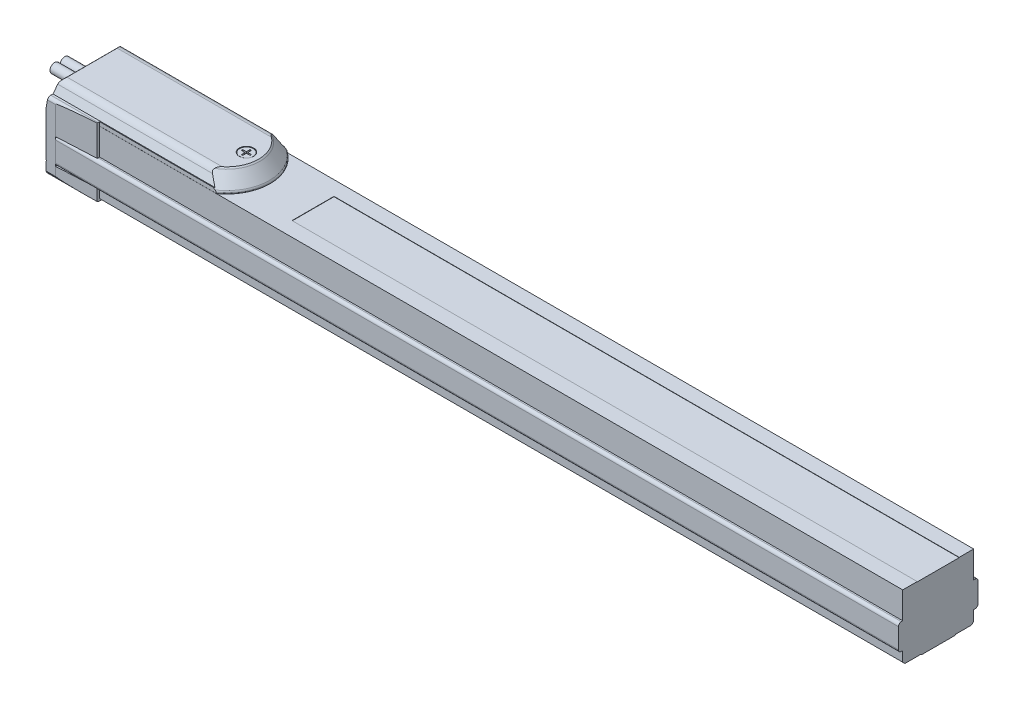
from build123d import *

# Parameters (mm, degrees)
BOSS_EXTRUDE1_DEPTH          = 930
SKETCH2_W                    = 204.786284779
SKETCH2_H                    = 168.647528641
CUT_EXTRUDE1_DEPTH           = 909.5
SKETCH3_W                    = 400
SKETCH3_H                    = 200
CUT_EXTRUDE2_DEPTH           = 930
BOSS_EXTRUDE2_DEPTH          = 127.35
CUT_REVOLVE1_ANGLE           = 75
CUT_REVOLVE1_OTHER_WAY_ANGLE = 75
CUT_EXTRUDE4_DEPTH           = 20
CUT_EXTRUDE5_DEPTH           = 1
CUT_EXTRUDE6_DEPTH           = 20
CUT_EXTRUDE6_DEPTH_BACK      = 20
CUT_EXTRUDE7_DEPTH           = 6
BOSS_EXTRUDE8_DEPTH          = 21.2
CUT_EXTRUDE9_DEPTH           = 30
CUT_EXTRUDE9_DEPTH_BACK      = 30
CUT_EXTRUDE10_DEPTH          = 2
CUT_EXTRUDE10_DEPTH_BACK     = 2
SKETCH14_R                   = 3.25
BOSS_EXTRUDE3_DEPTH          = 20
SKETCH15_R                   = 3.25
BOSS_EXTRUDE4_DEPTH          = 20
BOSS_EXTRUDE5_DEPTH          = 8.56
SKETCH17_W                   = 235.37802201
SKETCH17_H                   = 195.027503951
CUT_EXTRUDE14_DEPTH          = 40
BOSS_EXTRUDE6_DEPTH          = 18.5
BOSS_EXTRUDE7_DEPTH          = 8.56
SKETCH20_W                   = 235.37802201
SKETCH20_H                   = 195.027503951
CUT_EXTRUDE17_DEPTH          = 50
CUT_EXTRUDE18_DEPTH          = 3
SKETCH23_W                   = 742
SKETCH23_H                   = 29
CUT_EXTRUDE19_DEPTH          = 0.2
CUT_EXTRUDE20_DEPTH          = 25
CUT_EXTRUDE20_DEPTH_BACK     = 25
CUT_EXTRUDE21_DEPTH          = 16
CUT_EXTRUDE22_DEPTH          = 16
CUT_EXTRUDE23_DEPTH          = 34
CUT_EXTRUDE24_DEPTH          = 34
CUT_EXTRUDE25_DEPTH          = 16
CUT_EXTRUDE26_DEPTH          = 16
CUT_EXTRUDE27_DEPTH          = 12.5
CUT_EXTRUDE28_DEPTH          = 12.5
SKETCH_1_W                   = 185.367516804
SKETCH_1_H                   = 126.71742042
CUT_EXTRUDE_1_DEPTH          = 341


with BuildPart() as part:
    # Sketch1 → Boss-Extrude1 (new body)
    with BuildSketch(Plane(origin=(0, 0, 0), x_dir=(0, 0, -1), z_dir=(1, 0, 0))):
        with BuildLine():
            Line((-28.5, 46), (-28.5, 2.971392601))
            Line((-28.5, 2.971392601), (-27.5, 2.971392601))
            Line((-27.5, 2.971392601), (-27.328427125, 2.5))
            ThreePointArc((-27.328427125, 2.5), (-26.232050808, 1.050510257), (-24.5, 0.5))
            Line((-24.5, 0.5), (-12, 0.5))
            Line((-12, 0.5), (-11.5, 0))
            Line((-11.5, 0), (11.5, 0))
            Line((11.5, 0), (12, 0.5))
            Line((12, 0.5), (24.5, 0.5))
            ThreePointArc((24.5, 0.5), (26.232050808, 1.050510257), (27.328427125, 2.5))
            Line((27.328427125, 2.5), (27.5, 2.971392601))
            Line((27.5, 2.971392601), (28.5, 2.971392601))
            Line((28.5, 2.971392601), (28.5, 46))
            Line((28.5, 46), (27.5, 46))
            ThreePointArc((27.5, 46), (26.914213562, 47.414213562), (25.5, 48))
            Line((25.5, 48), (21.524012172, 48))
            ThreePointArc((21.524012172, 48), (17.477101448, 49.71603425), (13.295111884, 51.07))
            Line((13.295111884, 51.07), (-13.295111884, 51.07))
            ThreePointArc((-13.295111884, 51.07), (-17.477101448, 49.71603425), (-21.524012172, 48))
            Line((-21.524012172, 48), (-25.5, 48))
            ThreePointArc((-25.5, 48), (-26.914213562, 47.414213562), (-27.5, 46))
            Line((-27.5, 46), (-28.5, 46))
        make_face()
    extrude(amount=BOSS_EXTRUDE1_DEPTH)

    # Sketch2 → Cut-Extrude1 (cut)
    with BuildSketch(Plane(origin=(916, 0, 0), x_dir=(0, 0, -1), z_dir=(1, 0, 0))):
        with Locations((9.532349098, 15.424002622)):
            Rectangle(SKETCH2_W, SKETCH2_H)
        with BuildLine():
            Line((-27.5, 24.8), (-27.5, 11))
            ThreePointArc((-27.5, 11), (-26.914213562, 9.585786438), (-25.5, 9))
            Line((-25.5, 9), (-24.5, 9))
            Line((-24.5, 9), (-24.5, 2))
            Line((-24.5, 2), (-22.5, 0))
            Line((-22.5, 0), (22.5, 0))
            Line((22.5, 0), (24.5, 2))
            Line((24.5, 2), (24.5, 9))
            Line((24.5, 9), (25.5, 9))
            ThreePointArc((25.5, 9), (26.914213562, 9.585786438), (27.5, 11))
            Line((27.5, 11), (27.5, 24.8))
            ThreePointArc((27.5, 24.8), (26.914213562, 26.214213562), (25.5, 26.8))
            Line((25.5, 26.8), (24.5, 26.8))
            Line((24.5, 26.8), (24.5, 45.3))
            Line((24.5, 45.3), (-24.5, 45.3))
            Line((-24.5, 45.3), (-24.5, 26.8))
            Line((-24.5, 26.8), (-25.5, 26.8))
            ThreePointArc((-25.5, 26.8), (-26.914213562, 26.214213562), (-27.5, 24.8))
        make_face(mode=Mode.SUBTRACT)
    extrude(amount=-CUT_EXTRUDE1_DEPTH, mode=Mode.SUBTRACT)

    # Sketch3 → Cut-Extrude2 (cut)
    with BuildSketch(Plane(origin=(0, 0, 0), x_dir=(0, 0, -1), z_dir=(1, 0, 0))):
        Rectangle(SKETCH3_W, SKETCH3_H)
        with BuildLine():
            Line((-27.5, 46), (-27.5, 2.971392601))
            Line((-27.5, 2.971392601), (-27.328427125, 2.5))
            ThreePointArc((-27.328427125, 2.5), (-26.232050808, 1.050510257), (-24.5, 0.5))
            Line((-24.5, 0.5), (-12, 0.5))
            Line((-12, 0.5), (-11.5, 0))
            Line((-11.5, 0), (11.5, 0))
            Line((11.5, 0), (12, 0.5))
            Line((12, 0.5), (24.5, 0.5))
            ThreePointArc((24.5, 0.5), (26.232050808, 1.050510257), (27.328427125, 2.5))
            Line((27.328427125, 2.5), (27.5, 2.971392601))
            Line((27.5, 2.971392601), (27.5, 46))
            ThreePointArc((27.5, 46), (26.914213562, 47.414213562), (25.5, 48))
            Line((25.5, 48), (21.524012172, 48))
            ThreePointArc((21.524012172, 48), (17.477101448, 49.71603425), (13.295111884, 51.07))
            Line((13.295111884, 51.07), (-13.295111884, 51.07))
            ThreePointArc((-13.295111884, 51.07), (-17.477101448, 49.71603425), (-21.524012172, 48))
            Line((-21.524012172, 48), (-25.5, 48))
            ThreePointArc((-25.5, 48), (-26.914213562, 47.414213562), (-27.5, 46))
        make_face(mode=Mode.SUBTRACT)
    extrude(amount=CUT_EXTRUDE2_DEPTH, mode=Mode.SUBTRACT)

    # Sketch4 → Boss-Extrude2 (add)
    with BuildSketch(Plane(origin=(0, 0, 0), x_dir=(0, 0, -1), z_dir=(1, 0, 0))):
        with BuildLine():
            Line((-24.5, 30), (24.5, 30))
            Line((24.5, 30), (24.5, 45.3))
            Line((24.5, 45.3), (24.45, 45.3))
            Line((24.45, 45.3), (24.5, 45.35))
            Line((24.5, 45.35), (24.5, 48))
            Line((24.5, 48), (24, 48))
            Line((24, 48), (22.285663539, 52.710100717))
            ThreePointArc((22.285663539, 52.710100717), (20.455082617, 55.095760221), (17.587200435, 56))
            Line((17.587200435, 56), (-17.084187431, 56))
            ThreePointArc((-17.084187431, 56), (-19.770685472, 55.216957229), (-21.615726366, 53.113091309))
            Line((-21.615726366, 53.113091309), (-24, 48))
            Line((-24, 48), (-24.5, 48))
            Line((-24.5, 48), (-24.5, 45.35))
            Line((-24.5, 45.35), (-24.45, 45.3))
            Line((-24.45, 45.3), (-24.5, 45.3))
            Line((-24.5, 45.3), (-24.5, 30))
        make_face()
    extrude(amount=BOSS_EXTRUDE2_DEPTH)

    # Sketch5 → Cut-Revolve1 (revolve, cut)
    with BuildSketch(Plane.XY):
        with BuildLine():
            Line((97.35, 71.971261171), (150, 71.971261171))
            Line((150, 71.971261171), (150, 45.3))
            Line((150, 45.3), (127.35, 45.3))
            Line((127.35, 45.3), (127.35, 45.79))
            ThreePointArc((127.35, 45.79), (127.234272347, 46.460460828), (126.900482278, 47.053330799))
            Line((126.900482278, 47.053330799), (120.296542673, 55.158326997))
            ThreePointArc((120.296542673, 55.158326997), (118.566072869, 56.516172881), (116.420336979, 57))
            Line((116.420336979, 57), (97.35, 57))
            Line((97.35, 57), (97.35, 71.971261171))
        make_face()
    revolve(axis=Axis((97.35, 57, 0), (0, 1, 0)), revolution_arc=CUT_REVOLVE1_ANGLE, mode=Mode.SUBTRACT)

    # Sketch5 → Cut-Revolve1 other way (revolve, cut)
    with BuildSketch(Plane.XY):
        with BuildLine():
            Line((97.35, 71.971261171), (150, 71.971261171))
            Line((150, 71.971261171), (150, 45.3))
            Line((150, 45.3), (127.35, 45.3))
            Line((127.35, 45.3), (127.35, 45.79))
            ThreePointArc((127.35, 45.79), (127.234272347, 46.460460828), (126.900482278, 47.053330799))
            Line((126.900482278, 47.053330799), (120.296542673, 55.158326997))
            ThreePointArc((120.296542673, 55.158326997), (118.566072869, 56.516172881), (116.420336979, 57))
            Line((116.420336979, 57), (97.35, 57))
            Line((97.35, 57), (97.35, 71.971261171))
        make_face()
    revolve(axis=Axis((97.35, 57, 0), (0, -1, 0)), revolution_arc=CUT_REVOLVE1_OTHER_WAY_ANGLE, mode=Mode.SUBTRACT)

    # Sketch6 → Cut-Extrude4 (cut)
    with BuildSketch(Plane(origin=(0, 48, 0), x_dir=(-1, 0, 0), z_dir=(0, 1, 0))):
        Polygon((-916, 8.7), (-916.72022238, 8.7), (-926.5, 3.5), (-926.5, -3.5), (-916.72022238, -8.7), (-916, -8.7), align=None)
    extrude(amount=CUT_EXTRUDE4_DEPTH, mode=Mode.SUBTRACT)

    # Sketch7 → Revolve1 (revolve)
    with BuildSketch(Plane.XY):
        Polygon((921.5, 48), (918.5, 48), (918.5, 50.292893219), (919.207106781, 51), (921.5, 51), align=None)
    revolve(axis=Axis((921.5, 51, 0), (0, -1, 0)))

    # Sketch8 → Cut-Extrude5 (cut)
    with BuildSketch(Plane(origin=(0, 51, 0), x_dir=(-1, 0, 0), z_dir=(0, 1, 0))):
        with BuildLine():
            Line((-923.071623365, -0.3), (-921.8, -0.3))
            Line((-921.8, -0.3), (-921.8, -1.571623365))
            ThreePointArc((-921.8, -1.571623365), (-921.5, -1.6), (-921.2, -1.571623365))
            Line((-921.2, -1.571623365), (-921.2, -0.3))
            Line((-921.2, -0.3), (-919.928376635, -0.3))
            ThreePointArc((-919.928376635, -0.3), (-919.9, 0), (-919.928376635, 0.3))
            Line((-919.928376635, 0.3), (-921.2, 0.3))
            Line((-921.2, 0.3), (-921.2, 1.571623365))
            ThreePointArc((-921.2, 1.571623365), (-921.5, 1.6), (-921.8, 1.571623365))
            Line((-921.8, 1.571623365), (-921.8, 0.3))
            Line((-921.8, 0.3), (-923.071623365, 0.3))
            ThreePointArc((-923.071623365, 0.3), (-923.1, 0), (-923.071623365, -0.3))
        make_face()
    extrude(amount=-CUT_EXTRUDE5_DEPTH, mode=Mode.SUBTRACT)

    # Sketch9 → Cut-Extrude6 (cut, two sides)
    with BuildSketch(Plane.XY) as cut_extrude6_sk:
        Polygon((-50, 0.5), (-50, 0), (79, 0), (78.5, 0.5), align=None)
    extrude(amount=CUT_EXTRUDE6_DEPTH, mode=Mode.SUBTRACT)
    extrude(cut_extrude6_sk.sketch, amount=-CUT_EXTRUDE6_DEPTH_BACK, mode=Mode.SUBTRACT)

    # Sketch10 → Cut-Extrude7 (cut)
    with BuildSketch(Plane(origin=(0, 0, 0), x_dir=(-1, 0, 0), z_dir=(0, 1, 0))):
        with BuildLine():
            Line((-625.5, 2), (-627.5, 2))
            ThreePointArc((-627.5, 2), (-629.5, 0), (-627.5, -2))
            Line((-627.5, -2), (-625.5, -2))
            ThreePointArc((-625.5, -2), (-623.5, 0), (-625.5, 2))
        make_face()
    extrude(amount=CUT_EXTRUDE7_DEPTH, mode=Mode.SUBTRACT)

    # Sketch11 → Boss-Extrude8 (add)
    with BuildSketch(Plane(origin=(0, 26.8, 0), x_dir=(-1, 0, 0), z_dir=(0, 1, 0))):
        Polygon((0, 27.5), (-6, 27.5), (-34, 26.1), (-34, -26.1), (-6, -27.5), (0, -27.5), align=None)
    extrude(amount=BOSS_EXTRUDE8_DEPTH)

    # Sketch12 → Cut-Extrude9 (cut, two sides)
    with BuildSketch(Plane.XY) as cut_extrude9_sk:
        with BuildLine():
            Line((-20, -15), (15, -15))
            Line((15, -15), (15, 0))
            Line((15, 0), (5.587775501, 0))
            ThreePointArc((5.587775501, 0), (2.209824463, 1.313613316), (0.60680201, 4.564221286))
            Line((0.60680201, 4.564221286), (0, 11.5))
            Line((0, 11.5), (0, 40.45))
            Line((0, 40.45), (2.189670922, 52.868240888))
            ThreePointArc((2.189670922, 52.868240888), (3.899771638, 55.830222216), (7.113709687, 57))
            Line((7.113709687, 57), (15, 57))
            Line((15, 57), (15, 60))
            Line((15, 60), (-20, 60))
            Line((-20, 60), (-20, -15))
        make_face()
    extrude(amount=CUT_EXTRUDE9_DEPTH, mode=Mode.SUBTRACT)
    extrude(cut_extrude9_sk.sketch, amount=-CUT_EXTRUDE9_DEPTH_BACK, mode=Mode.SUBTRACT)

    # Sketch13 → Cut-Extrude10 (cut, two sides)
    with BuildSketch(Plane(origin=(0, 0, 0), x_dir=(0, 0, -1), z_dir=(1, 0, 0))) as cut_extrude10_sk:
        with BuildLine():
            Line((-10, 46.95), (-10, 42.95))
            ThreePointArc((-10, 42.95), (-8.535533906, 39.414466094), (-5, 37.95))
            Line((-5, 37.95), (5, 37.95))
            ThreePointArc((5, 37.95), (8.535533906, 39.414466094), (10, 42.95))
            Line((10, 42.95), (10, 46.95))
            ThreePointArc((10, 46.95), (9.707106781, 47.657106781), (9, 47.95))
            Line((9, 47.95), (-9, 47.95))
            ThreePointArc((-9, 47.95), (-9.707106781, 47.657106781), (-10, 46.95))
        make_face()
    extrude(amount=CUT_EXTRUDE10_DEPTH, mode=Mode.SUBTRACT)
    extrude(cut_extrude10_sk.sketch, amount=-CUT_EXTRUDE10_DEPTH_BACK, mode=Mode.SUBTRACT)

    # Sketch14 → Boss-Extrude3 (add)
    with BuildSketch(Plane(origin=(2, 0, 0), x_dir=(0, 0, -1), z_dir=(1, 0, 0))):
        with Locations((-3.5, 43.7)):
            Circle(SKETCH14_R)
    extrude(amount=-BOSS_EXTRUDE3_DEPTH)

    # Sketch15 → Boss-Extrude4 (add)
    with BuildSketch(Plane(origin=(2, 0, 0), x_dir=(0, 0, -1), z_dir=(1, 0, 0))):
        with Locations((3.5, 43.7)):
            Circle(SKETCH15_R)
    extrude(amount=-BOSS_EXTRUDE4_DEPTH)

    # Sketch16 → Boss-Extrude5 (add)
    with BuildSketch(Plane(origin=(0, 9, 0), x_dir=(-1, 0, 0), z_dir=(0, 1, 0))):
        Polygon((0, 27.5), (-6, 27.5), (-34, 26.1), (-34, -26.1), (-6, -27.5), (0, -27.5), align=None)
    extrude(amount=-BOSS_EXTRUDE5_DEPTH)

    # Sketch17 → Cut-Extrude14 (cut)
    with BuildSketch(Plane(origin=(0, 0, 0), x_dir=(0, 0, -1), z_dir=(1, 0, 0))):
        with Locations((8.296344577, 18.152881027)):
            Rectangle(SKETCH17_W, SKETCH17_H)
        with BuildLine():
            Line((-27.5, 46), (-27.5, 2.971392601))
            Line((-27.5, 2.971392601), (-27.328427125, 2.5))
            ThreePointArc((-27.328427125, 2.5), (-26.232050808, 1.050510257), (-24.5, 0.5))
            Line((-24.5, 0.5), (24.5, 0.5))
            ThreePointArc((24.5, 0.5), (26.232050808, 1.050510257), (27.328427125, 2.5))
            Line((27.328427125, 2.5), (27.5, 2.971392601))
            Line((27.5, 2.971392601), (27.5, 46))
            ThreePointArc((27.5, 46), (26.914213562, 47.414213562), (25.5, 48))
            Line((25.5, 48), (24, 48))
            Line((24, 48), (24, 65))
            Line((24, 65), (-24, 65))
            Line((-24, 65), (-24, 48))
            Line((-24, 48), (-25.5, 48))
            ThreePointArc((-25.5, 48), (-26.914213562, 47.414213562), (-27.5, 46))
        make_face(mode=Mode.SUBTRACT)
    extrude(amount=CUT_EXTRUDE14_DEPTH, mode=Mode.SUBTRACT)

    # Sketch18 → Boss-Extrude6 (add)
    with BuildSketch(Plane(origin=(0, 26.8, 0), x_dir=(-1, 0, 0), z_dir=(0, 1, 0))):
        Polygon((-889, 26.1), (-917, 27.5), (-923, 27.5), (-923, -27.5), (-917, -27.5), (-889, -26.1), align=None)
    extrude(amount=BOSS_EXTRUDE6_DEPTH)

    # Sketch19 → Boss-Extrude7 (add)
    with BuildSketch(Plane(origin=(0, 9, 0), x_dir=(-1, 0, 0), z_dir=(0, 1, 0))):
        Polygon((-889, 26.1), (-917, 27.5), (-930, 27.5), (-930, -27.5), (-917, -27.5), (-889, -26.1), align=None)
    extrude(amount=-BOSS_EXTRUDE7_DEPTH)

    # Sketch20 → Cut-Extrude17 (cut)
    with BuildSketch(Plane(origin=(930, 0, 0), x_dir=(0, 0, -1), z_dir=(1, 0, 0))):
        with Locations((8.296344577, 18.152881027)):
            Rectangle(SKETCH20_W, SKETCH20_H)
        with BuildLine():
            Line((-27.5, 46), (-27.5, 2.971392601))
            Line((-27.5, 2.971392601), (-27.328427125, 2.5))
            ThreePointArc((-27.328427125, 2.5), (-26.232050808, 1.050510257), (-24.5, 0.5))
            Line((-24.5, 0.5), (-12, 0.5))
            Line((-12, 0.5), (-11.5, 0))
            Line((-11.5, 0), (11.5, 0))
            Line((11.5, 0), (12, 0.5))
            Line((12, 0.5), (24.5, 0.5))
            ThreePointArc((24.5, 0.5), (26.232050808, 1.050510257), (27.328427125, 2.5))
            Line((27.328427125, 2.5), (27.5, 2.971392601))
            Line((27.5, 2.971392601), (27.5, 46))
            ThreePointArc((27.5, 46), (26.914213562, 47.414213562), (25.5, 48))
            Line((25.5, 48), (24, 48))
            Line((24, 48), (24, 65))
            Line((24, 65), (-24, 65))
            Line((-24, 65), (-24, 48))
            Line((-24, 48), (-25.5, 48))
            ThreePointArc((-25.5, 48), (-26.914213562, 47.414213562), (-27.5, 46))
        make_face(mode=Mode.SUBTRACT)
    extrude(amount=-CUT_EXTRUDE17_DEPTH, mode=Mode.SUBTRACT)

    # Sketch21 → Cut-Revolve2 (revolve, cut)
    with BuildSketch(Plane.XY):
        Polygon((111, 60.83306822), (116, 60.83306822), (116, 55.5), (115.7, 55.8), (111, 55.8), align=None)
    revolve(axis=Axis((111, 55.8, 0), (0, 1, 0)), mode=Mode.SUBTRACT)

    # Sketch22 → Cut-Extrude18 (cut)
    with BuildSketch(Plane(origin=(0, 55.8, 0), x_dir=(-1, 0, 0), z_dir=(0, 1, 0))):
        with BuildLine():
            Line((-108.041960108, 0.5), (-110.5, 0.5))
            Line((-110.5, 0.5), (-110.5, 2.958039892))
            ThreePointArc((-110.5, 2.958039892), (-111, 3), (-111.5, 2.958039892))
            Line((-111.5, 2.958039892), (-111.5, 0.5))
            Line((-111.5, 0.5), (-113.958039892, 0.5))
            ThreePointArc((-113.958039892, 0.5), (-114, 0), (-113.958039892, -0.5))
            Line((-113.958039892, -0.5), (-111.5, -0.5))
            Line((-111.5, -0.5), (-111.5, -2.958039892))
            ThreePointArc((-111.5, -2.958039892), (-111, -3), (-110.5, -2.958039892))
            Line((-110.5, -2.958039892), (-110.5, -0.5))
            Line((-110.5, -0.5), (-108.041960108, -0.5))
            ThreePointArc((-108.041960108, -0.5), (-108, 0), (-108.041960108, 0.5))
        make_face()
    extrude(amount=-CUT_EXTRUDE18_DEPTH, mode=Mode.SUBTRACT)

    # Sketch23 → Cut-Extrude19 (cut)
    with BuildSketch(Plane(origin=(0, 45.3, 0), x_dir=(-1, 0, 0), z_dir=(0, 1, 0))):
        with Locations((-528, 0)):
            Rectangle(SKETCH23_W, SKETCH23_H)
    extrude(amount=-CUT_EXTRUDE19_DEPTH, mode=Mode.SUBTRACT)

    # Sketch24 → Cut-Revolve3 (revolve, cut)
    with BuildSketch(Plane.XY):
        Polygon((126.5, 0), (124.5, 0), (124.5, 6), (126.5, 7.154700538), align=None)
    revolve(axis=Axis((126.5, 7.154700538, 0), (0, -1, 0)), mode=Mode.SUBTRACT)

    # Sketch25 → Cut-Revolve4 (revolve, cut)
    with BuildSketch(Plane(origin=(101.5, 0, 0), x_dir=(0, 0, -1), z_dir=(1, 0, 0))):
        Polygon((0, 11.019415637), (2.4585, 9.6), (2.4585, 0.5415), (3, 0), (0, 0), align=None)
    revolve(axis=Axis((101.5, 0, 0), (0, 1, 0)), mode=Mode.SUBTRACT)

    # Sketch26 → Cut-Revolve5 (revolve, cut)
    with BuildSketch(Plane(origin=(901.5, 0, 0), x_dir=(0, 0, -1), z_dir=(1, 0, 0))):
        Polygon((0, 11.019415637), (2.4585, 9.6), (2.4585, 0.5415), (3, 0), (0, 0), align=None)
    revolve(axis=Axis((901.5, 0, 0), (0, 1, 0)), mode=Mode.SUBTRACT)

    # Sketch27 → Cut-Revolve6 (revolve, cut)
    with BuildSketch(Plane(origin=(851.5, 0, 0), x_dir=(0, 0, -1), z_dir=(1, 0, 0))):
        Polygon((0, 11.019415637), (2.4585, 9.6), (2.4585, 0.5415), (3, 0), (0, 0), align=None)
    revolve(axis=Axis((851.5, 0, 0), (0, 1, 0)), mode=Mode.SUBTRACT)

    # Sketch28 → Cut-Revolve7 (revolve, cut)
    with BuildSketch(Plane(origin=(801.5, 0, 0), x_dir=(0, 0, -1), z_dir=(1, 0, 0))):
        Polygon((0, 11.019415637), (2.4585, 9.6), (2.4585, 0.5415), (3, 0), (0, 0), align=None)
    revolve(axis=Axis((801.5, 0, 0), (0, 1, 0)), mode=Mode.SUBTRACT)

    # Sketch29 → Cut-Revolve8 (revolve, cut)
    with BuildSketch(Plane(origin=(751.5, 0, 0), x_dir=(0, 0, -1), z_dir=(1, 0, 0))):
        Polygon((0, 11.019415637), (2.4585, 9.6), (2.4585, 0.5415), (3, 0), (0, 0), align=None)
    revolve(axis=Axis((751.5, 0, 0), (0, 1, 0)), mode=Mode.SUBTRACT)

    # Sketch30 → Cut-Revolve9 (revolve, cut)
    with BuildSketch(Plane(origin=(701.5, 0, 0), x_dir=(0, 0, -1), z_dir=(1, 0, 0))):
        Polygon((0, 11.019415637), (2.4585, 9.6), (2.4585, 0.5415), (3, 0), (0, 0), align=None)
    revolve(axis=Axis((701.5, 0, 0), (0, 1, 0)), mode=Mode.SUBTRACT)

    # Sketch31 → Cut-Revolve10 (revolve, cut)
    with BuildSketch(Plane(origin=(651.5, 0, 0), x_dir=(0, 0, -1), z_dir=(1, 0, 0))):
        Polygon((0, 11.019415637), (2.4585, 9.6), (2.4585, 0.5415), (3, 0), (0, 0), align=None)
    revolve(axis=Axis((651.5, 0, 0), (0, 1, 0)), mode=Mode.SUBTRACT)

    # Sketch32 → Cut-Revolve11 (revolve, cut)
    with BuildSketch(Plane(origin=(601.5, 0, 0), x_dir=(0, 0, -1), z_dir=(1, 0, 0))):
        Polygon((0, 11.019415637), (2.4585, 9.6), (2.4585, 0.5415), (3, 0), (0, 0), align=None)
    revolve(axis=Axis((601.5, 0, 0), (0, 1, 0)), mode=Mode.SUBTRACT)

    # Sketch33 → Cut-Revolve12 (revolve, cut)
    with BuildSketch(Plane(origin=(551.5, 0, 0), x_dir=(0, 0, -1), z_dir=(1, 0, 0))):
        Polygon((0, 11.019415637), (2.4585, 9.6), (2.4585, 0.5415), (3, 0), (0, 0), align=None)
    revolve(axis=Axis((551.5, 0, 0), (0, 1, 0)), mode=Mode.SUBTRACT)

    # Sketch34 → Cut-Revolve13 (revolve, cut)
    with BuildSketch(Plane(origin=(501.5, 0, 0), x_dir=(0, 0, -1), z_dir=(1, 0, 0))):
        Polygon((0, 11.019415637), (2.4585, 9.6), (2.4585, 0.5415), (3, 0), (0, 0), align=None)
    revolve(axis=Axis((501.5, 0, 0), (0, 1, 0)), mode=Mode.SUBTRACT)

    # Sketch35 → Cut-Revolve14 (revolve, cut)
    with BuildSketch(Plane(origin=(451.5, 0, 0), x_dir=(0, 0, -1), z_dir=(1, 0, 0))):
        Polygon((0, 11.019415637), (2.4585, 9.6), (2.4585, 0.5415), (3, 0), (0, 0), align=None)
    revolve(axis=Axis((451.5, 0, 0), (0, 1, 0)), mode=Mode.SUBTRACT)

    # Sketch36 → Cut-Revolve15 (revolve, cut)
    with BuildSketch(Plane(origin=(401.5, 0, 0), x_dir=(0, 0, -1), z_dir=(1, 0, 0))):
        Polygon((0, 11.019415637), (2.4585, 9.6), (2.4585, 0.5415), (3, 0), (0, 0), align=None)
    revolve(axis=Axis((401.5, 0, 0), (0, 1, 0)), mode=Mode.SUBTRACT)

    # Sketch37 → Cut-Revolve16 (revolve, cut)
    with BuildSketch(Plane(origin=(351.5, 0, 0), x_dir=(0, 0, -1), z_dir=(1, 0, 0))):
        Polygon((0, 11.019415637), (2.4585, 9.6), (2.4585, 0.5415), (3, 0), (0, 0), align=None)
    revolve(axis=Axis((351.5, 0, 0), (0, 1, 0)), mode=Mode.SUBTRACT)

    # Sketch38 → Cut-Revolve17 (revolve, cut)
    with BuildSketch(Plane(origin=(301.5, 0, 0), x_dir=(0, 0, -1), z_dir=(1, 0, 0))):
        Polygon((0, 11.019415637), (2.4585, 9.6), (2.4585, 0.5415), (3, 0), (0, 0), align=None)
    revolve(axis=Axis((301.5, 0, 0), (0, 1, 0)), mode=Mode.SUBTRACT)

    # Sketch39 → Cut-Revolve18 (revolve, cut)
    with BuildSketch(Plane(origin=(251.5, 0, 0), x_dir=(0, 0, -1), z_dir=(1, 0, 0))):
        Polygon((0, 11.019415637), (2.4585, 9.6), (2.4585, 0.5415), (3, 0), (0, 0), align=None)
    revolve(axis=Axis((251.5, 0, 0), (0, 1, 0)), mode=Mode.SUBTRACT)

    # Sketch40 → Cut-Revolve19 (revolve, cut)
    with BuildSketch(Plane(origin=(201.5, 0, 0), x_dir=(0, 0, -1), z_dir=(1, 0, 0))):
        Polygon((0, 11.019415637), (2.4585, 9.6), (2.4585, 0.5415), (3, 0), (0, 0), align=None)
    revolve(axis=Axis((201.5, 0, 0), (0, 1, 0)), mode=Mode.SUBTRACT)

    # Sketch41 → Cut-Revolve20 (revolve, cut)
    with BuildSketch(Plane(origin=(151.5, 0, 0), x_dir=(0, 0, -1), z_dir=(1, 0, 0))):
        Polygon((0, 11.019415637), (2.4585, 9.6), (2.4585, 0.5415), (3, 0), (0, 0), align=None)
    revolve(axis=Axis((151.5, 0, 0), (0, 1, 0)), mode=Mode.SUBTRACT)

    # Sketch42 → Cut-Extrude20 (cut, two sides)
    with BuildSketch(Plane.XY) as cut_extrude20_sk:
        Polygon((34, 0.5), (34.05, 0.5), (34, 0.55), align=None)
    extrude(amount=CUT_EXTRUDE20_DEPTH, mode=Mode.SUBTRACT)
    extrude(cut_extrude20_sk.sketch, amount=-CUT_EXTRUDE20_DEPTH_BACK, mode=Mode.SUBTRACT)

    # Sketch43 → Cut-Extrude21 (cut)
    with BuildSketch(Plane(origin=(0, 26.8, 0), x_dir=(-1, 0, 0), z_dir=(0, 1, 0))):
        Polygon((-6.5, 27.5), (-6.55, 27.5), (-6.5, 27.45), align=None)
    extrude(amount=-CUT_EXTRUDE21_DEPTH, mode=Mode.SUBTRACT)

    # Sketch44 → Cut-Extrude22 (cut)
    with BuildSketch(Plane(origin=(0, 26.8, 0), x_dir=(-1, 0, 0), z_dir=(0, 1, 0))):
        Polygon((-6.5, -27.5), (-6.5, -27.45), (-6.55, -27.5), align=None)
    extrude(amount=-CUT_EXTRUDE22_DEPTH, mode=Mode.SUBTRACT)

    # Sketch45 → Cut-Extrude23 (cut)
    with BuildSketch(Plane(origin=(916, 0, 0), x_dir=(0, 0, -1), z_dir=(1, 0, 0))):
        Polygon((-24.558, 45.3), (-24.5, 45.25), (-24.5, 45.3), align=None)
    extrude(amount=-CUT_EXTRUDE23_DEPTH, mode=Mode.SUBTRACT)

    # Sketch46 → Cut-Extrude24 (cut)
    with BuildSketch(Plane(origin=(916, 0, 0), x_dir=(0, 0, -1), z_dir=(1, 0, 0))):
        Polygon((24.5, 45.25), (24.558, 45.3), (24.5, 45.3), align=None)
    extrude(amount=-CUT_EXTRUDE24_DEPTH, mode=Mode.SUBTRACT)

    # Sketch47 → Cut-Extrude25 (cut)
    with BuildSketch(Plane(origin=(0, 26.8, 0), x_dir=(-1, 0, 0), z_dir=(0, 1, 0))):
        Polygon((-915.95, 27.5), (-916, 27.5), (-916, 27.45), align=None)
    extrude(amount=-CUT_EXTRUDE25_DEPTH, mode=Mode.SUBTRACT)

    # Sketch48 → Cut-Extrude26 (cut)
    with BuildSketch(Plane(origin=(0, 26.8, 0), x_dir=(-1, 0, 0), z_dir=(0, 1, 0))):
        Polygon((-915.95, -27.5), (-916, -27.45), (-916, -27.5), align=None)
    extrude(amount=-CUT_EXTRUDE26_DEPTH, mode=Mode.SUBTRACT)

    # Sketch49 → Cut-Extrude27 (cut)
    with BuildSketch(Plane.XY.offset(24.5)):
        Polygon((888.95, 0.5), (889, 0.5), (889, 0.55), align=None)
    extrude(amount=-CUT_EXTRUDE27_DEPTH, mode=Mode.SUBTRACT)

    # Sketch50 → Cut-Extrude28 (cut)
    with BuildSketch(Plane.XY.offset(-24.5)):
        Polygon((888.95, 0.5), (889, 0.5), (889, 0.55), align=None)
    extrude(amount=CUT_EXTRUDE28_DEPTH, mode=Mode.SUBTRACT)

    # Эскиз1 → Вырез-Вытянуть1 (cut)
    with BuildSketch(Plane(origin=(930, 0, 0), x_dir=(0, 0, -1), z_dir=(1, 0, 0))):
        with Locations((1.329004423, 33.558913214)):
            Rectangle(SKETCH_1_W, SKETCH_1_H)
    extrude(amount=-CUT_EXTRUDE_1_DEPTH, mode=Mode.SUBTRACT)


solid = part.part
